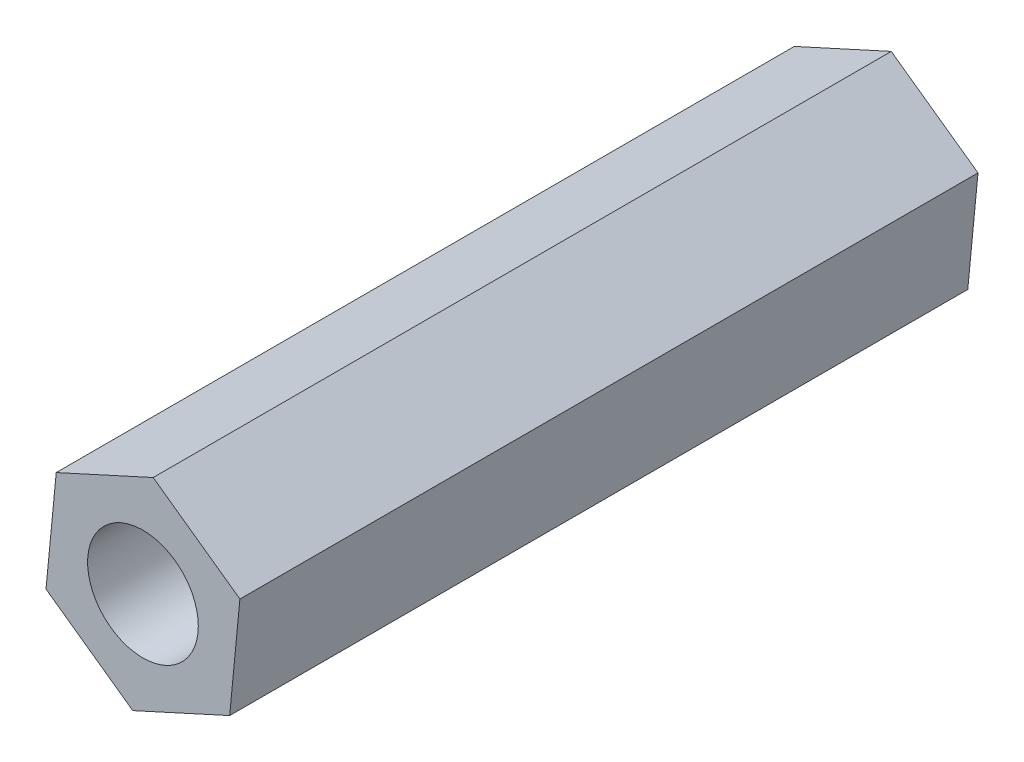
from build123d import *

# Parameters (mm, degrees)
SZKIC1_R                    = 1.5
DODANIE_WYCI_GNI_CIE1_DEPTH = 20


with BuildPart() as part:
    # Szkic1 → Dodanie-wyciągnięcie1 (new body)
    with BuildSketch(Plane.XY):
        Polygon((2.627001114, 1.196744952), (0.277089027, 2.873422177), (-2.349912087, 1.676677225), (-2.627001114, -1.196744952), (-0.277089027, -2.873422177), (2.349912087, -1.676677225), align=None)
        Circle(SZKIC1_R, mode=Mode.SUBTRACT)
    extrude(amount=DODANIE_WYCI_GNI_CIE1_DEPTH)


solid = part.part
